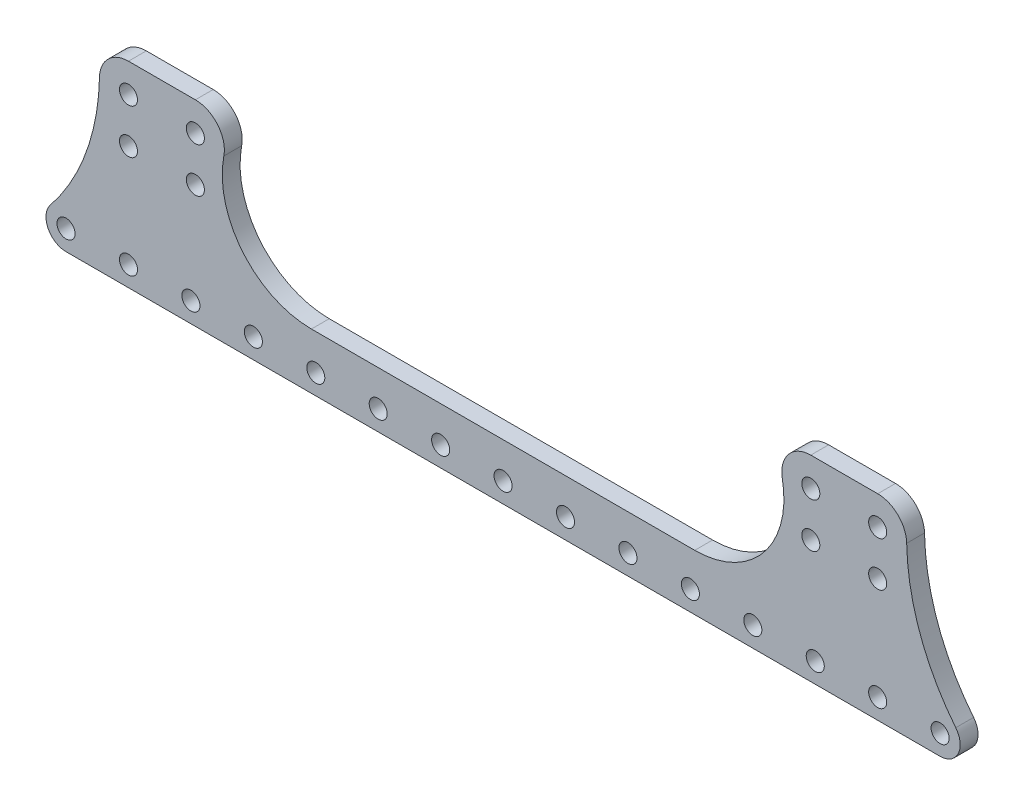
from build123d import *

# Parameters (mm, degrees)
SKETCH_1_R      = 2.025
EXTRUDE_1_DEPTH = 4


with BuildPart() as part:
    # 草图1 → 凸台-拉伸1 (new body)
    with BuildSketch(Plane.XY):
        with BuildLine():
            Line((-98, -32.5), (98, -32.5))
            ThreePointArc((98, -32.5), (102.057826292, -29.945262394), (101.508238617, -25.181798126))
            ThreePointArc((101.508238617, -25.181798126), (93.492529314, -10.937801768), (90.498696296, 5.130178558))
            ThreePointArc((90.498696296, 5.130178558), (88.549936229, 9.641990986), (84, 11.5))
            Line((84, 11.5), (69, 11.5))
            ThreePointArc((69, 11.5), (63.988927391, 9.13994581), (62.616747985, 3.773585019))
            ThreePointArc((62.616747985, 3.773585019), (58.39465774, -12.73829462), (42.975972641, -20))
            Line((42.975972641, -20), (-42.975972641, -20))
            ThreePointArc((-42.975972641, -20), (-58.394657646, -12.738294733), (-62.61674804, 3.773584731))
            ThreePointArc((-62.61674804, 3.773584731), (-63.988927298, 9.139945697), (-69, 11.5))
            Line((-69, 11.5), (-84, 11.5))
            ThreePointArc((-84, 11.5), (-88.549936232, 9.641990982), (-90.498696296, 5.130178548))
            ThreePointArc((-90.498696296, 5.130178548), (-93.492529331, -10.937801814), (-101.508238673, -25.181798195))
            ThreePointArc((-101.508238673, -25.181798195), (-102.057826273, -29.945262434), (-98, -32.5))
        make_face()
        with Locations((-84, -28)):
            Circle(SKETCH_1_R, mode=Mode.SUBTRACT)
        with Locations((84, -5)):
            Circle(SKETCH_1_R, mode=Mode.SUBTRACT)
        with Locations((69, -5)):
            Circle(SKETCH_1_R, mode=Mode.SUBTRACT)
        with Locations((-70, -28)):
            Circle(SKETCH_1_R, mode=Mode.SUBTRACT)
        with Locations((-56, -28)):
            Circle(SKETCH_1_R, mode=Mode.SUBTRACT)
        with Locations((-42, -28)):
            Circle(SKETCH_1_R, mode=Mode.SUBTRACT)
        with Locations((-28, -28)):
            Circle(SKETCH_1_R, mode=Mode.SUBTRACT)
        with Locations((-14, -28)):
            Circle(SKETCH_1_R, mode=Mode.SUBTRACT)
        with Locations((0, -28)):
            Circle(SKETCH_1_R, mode=Mode.SUBTRACT)
        with Locations((14, -28)):
            Circle(SKETCH_1_R, mode=Mode.SUBTRACT)
        with Locations((28, -28)):
            Circle(SKETCH_1_R, mode=Mode.SUBTRACT)
        with Locations((42, -28)):
            Circle(SKETCH_1_R, mode=Mode.SUBTRACT)
        with Locations((56, -28)):
            Circle(SKETCH_1_R, mode=Mode.SUBTRACT)
        with Locations((70, -28)):
            Circle(SKETCH_1_R, mode=Mode.SUBTRACT)
        with Locations((-84, -5)):
            Circle(SKETCH_1_R, mode=Mode.SUBTRACT)
        with Locations((-69, -5)):
            Circle(SKETCH_1_R, mode=Mode.SUBTRACT)
        with Locations((84, -28)):
            Circle(SKETCH_1_R, mode=Mode.SUBTRACT)
        with Locations((-98, -28)):
            Circle(SKETCH_1_R, mode=Mode.SUBTRACT)
        with Locations((-84, 5)):
            Circle(SKETCH_1_R, mode=Mode.SUBTRACT)
        with Locations((98, -28)):
            Circle(SKETCH_1_R, mode=Mode.SUBTRACT)
        with Locations((-69, 5)):
            Circle(SKETCH_1_R, mode=Mode.SUBTRACT)
        with Locations((84, 5)):
            Circle(SKETCH_1_R, mode=Mode.SUBTRACT)
        with Locations((69, 5)):
            Circle(SKETCH_1_R, mode=Mode.SUBTRACT)
    extrude(amount=EXTRUDE_1_DEPTH)


solid = part.part
